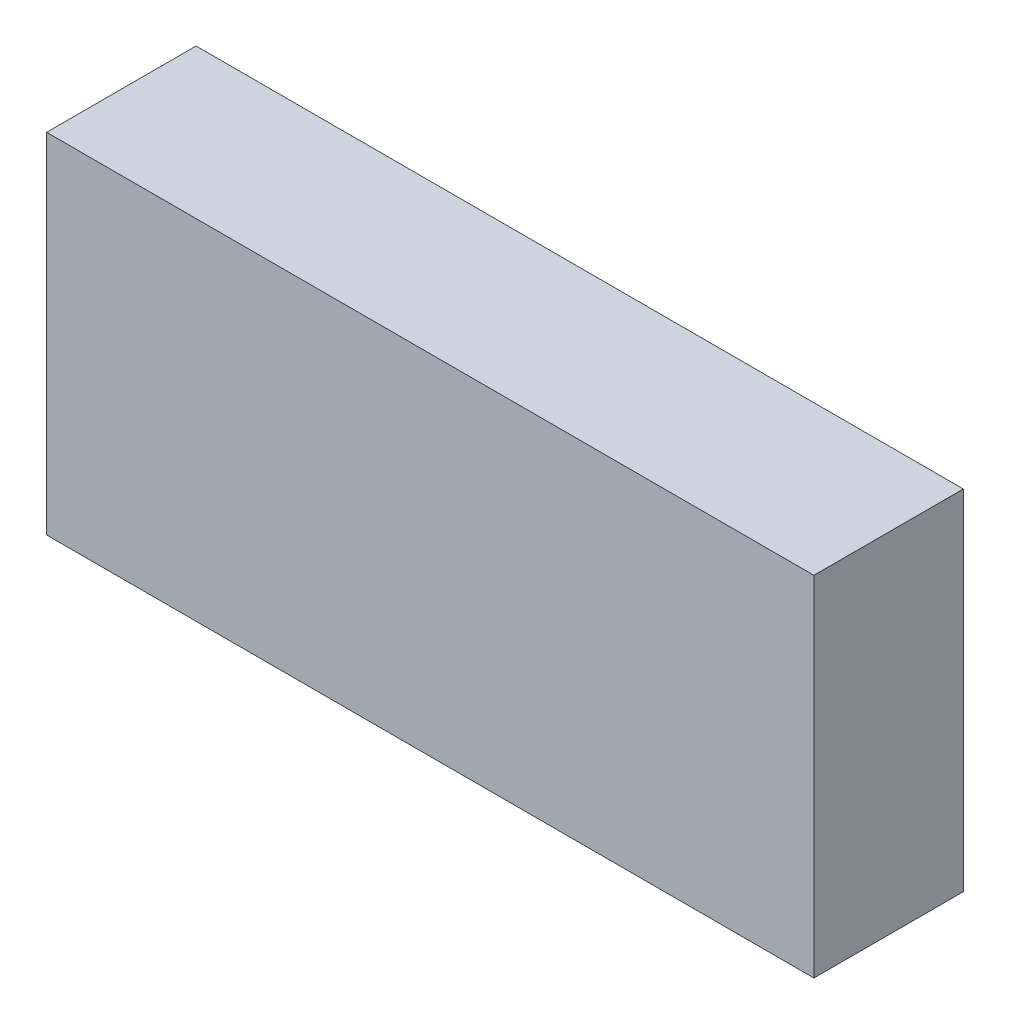
from build123d import *

# Parameters (mm, degrees)
SKETCH_1_W      = 77
SKETCH_1_H      = 35
EXTRUDE_1_DEPTH = 7.5


with BuildPart() as part:
    # Эскиз1 → Бобышка-Вытянуть1 (new body, symmetric)
    with BuildSketch(Plane.XY):
        Rectangle(SKETCH_1_W, SKETCH_1_H)
    extrude(amount=EXTRUDE_1_DEPTH, both=True)


solid = part.part
